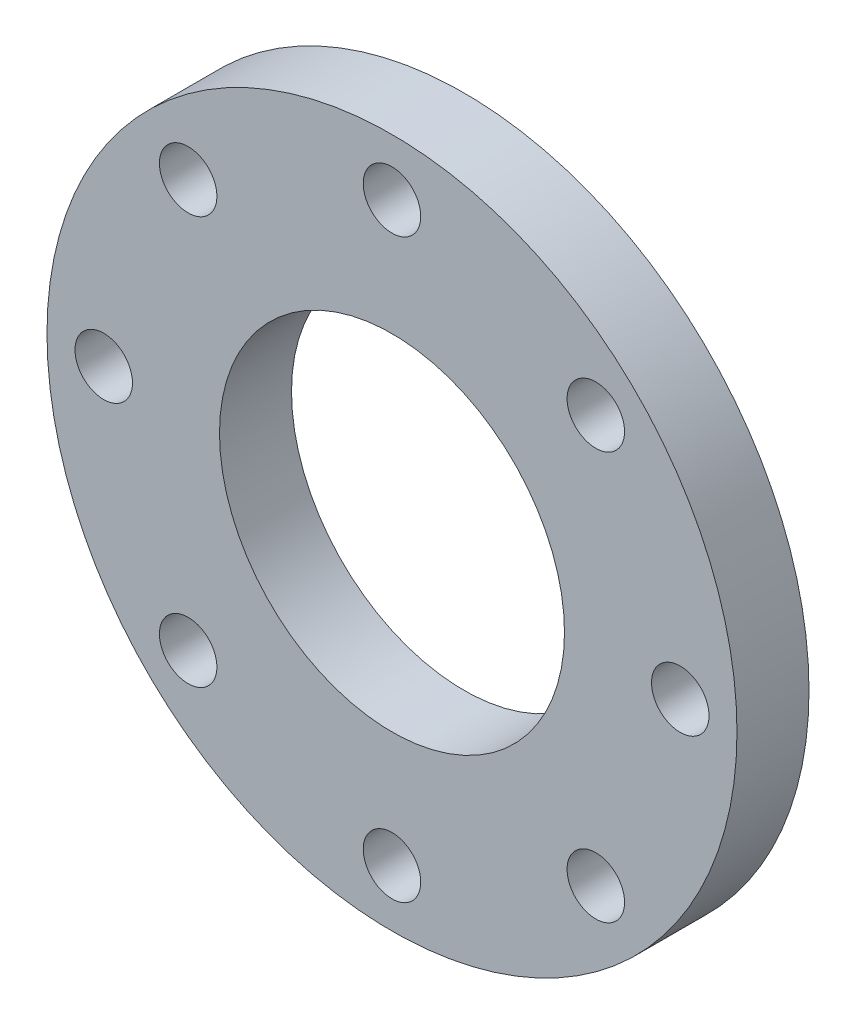
from build123d import *

# Parameters (mm, degrees)
SKETCH19_R          = 114
SKETCH19_R_2        = 57
SKETCH19_R_3        = 9.5
BOSS_EXTRUDE1_DEPTH = 23.8


with BuildPart() as part:
    # Sketch19 → Boss-Extrude1 (new body)
    with BuildSketch(Plane.XY):
        Circle(SKETCH19_R)
        Circle(SKETCH19_R_2, mode=Mode.SUBTRACT)
        with Locations((0, 95.25)):
            Circle(SKETCH19_R_3, mode=Mode.SUBTRACT)
        with Locations((67.351920908, 67.351920908)):
            Circle(SKETCH19_R_3, mode=Mode.SUBTRACT)
        with Locations((95.25, 0)):
            Circle(SKETCH19_R_3, mode=Mode.SUBTRACT)
        with Locations((67.351920908, -67.351920908)):
            Circle(SKETCH19_R_3, mode=Mode.SUBTRACT)
        with Locations((0, -95.25)):
            Circle(SKETCH19_R_3, mode=Mode.SUBTRACT)
        with Locations((-67.351920908, -67.351920908)):
            Circle(SKETCH19_R_3, mode=Mode.SUBTRACT)
        with Locations((-95.25, 0)):
            Circle(SKETCH19_R_3, mode=Mode.SUBTRACT)
        with Locations((-67.351920908, 67.351920908)):
            Circle(SKETCH19_R_3, mode=Mode.SUBTRACT)
    extrude(amount=BOSS_EXTRUDE1_DEPTH)


solid = part.part
